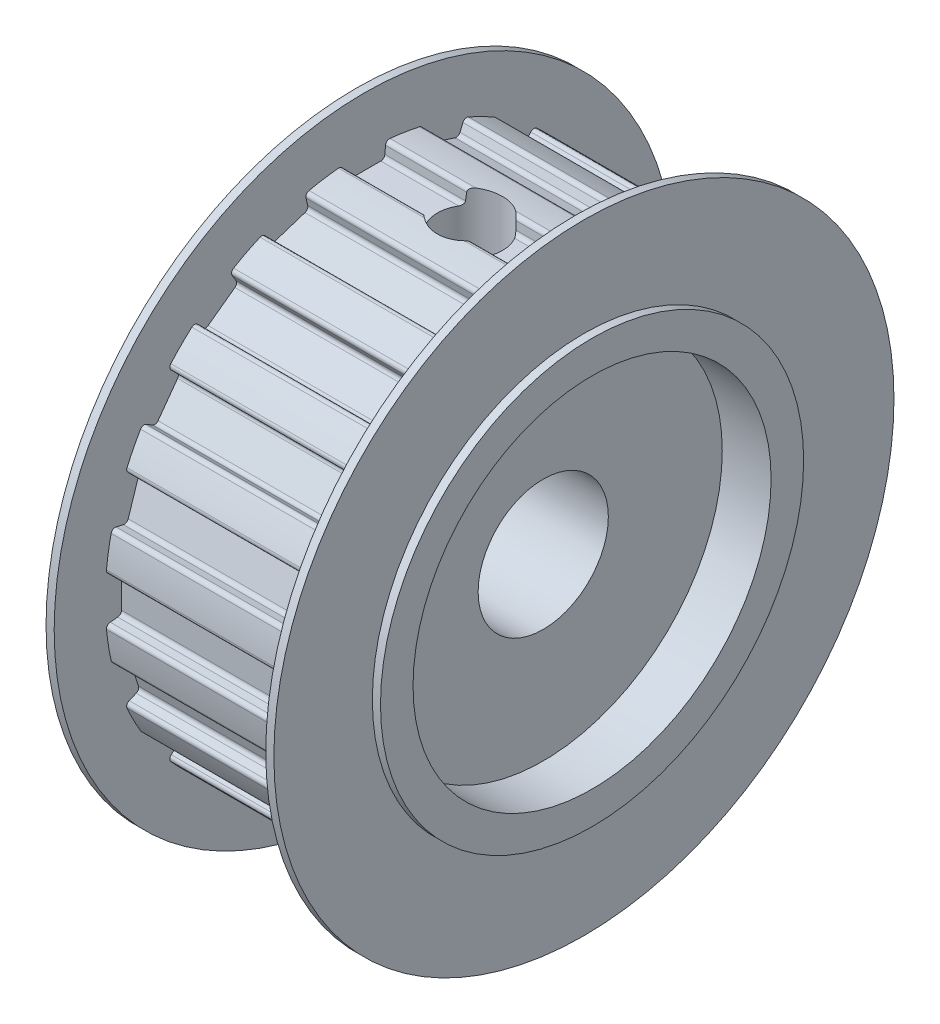
from build123d import *

# Parameters (mm, degrees)
ESQUISSE1_R                         = 15.915
EXTRUSION1_DEPTH                    = 13
ENL_V_MAT_EXTRU_2_DEPTH             = 13
CONG_1_R                            = 0.25
CONG_2_R                            = 0.25
CONG_3_R                            = 0.25
CONG_4_R                            = 0.25
R_P_TITION_CIRCULAIRE1_COUNT        = 20
CONG_1_OF_R_P_TITION_CIRCULAIRE1_R  = 0.25
CONG_2_OF_R_P_TITION_CIRCULAIRE1_R  = 0.25
CONG_3_OF_R_P_TITION_CIRCULAIRE1_R  = 0.25
CONG_4_OF_R_P_TITION_CIRCULAIRE1_R  = 0.25
ESQUISSE23_R                        = 19.05
EXTRUSION2_DEPTH                    = 1
ESQUISSE24_R                        = 19.05
EXTRUSION3_DEPTH                    = 1
ESQUISSE25_R                        = 4
ENL_V_MAT_EXTRU_3_DEPTH             = 16
ENL_V_MAT_EXTRU_5_REACH             = 35.965
ESQUISSE30_R                        = 2
ENL_V_MAT_EXTRU_5_DIRECTION_2_DEPTH = 5.135
ESQUISSE31_OUTSIDE_W                = 51.286
ESQUISSE31_OUTSIDE_H                = 51.286
ESQUISSE31_OUTSIDE_R                = 13
ENL_V_MAT_EXTRU_6_DEPTH             = 0.5
ESQUISSE32_OUTSIDE_W                = 51.286
ESQUISSE32_OUTSIDE_H                = 51.286
ESQUISSE32_OUTSIDE_R                = 13
ENL_V_MAT_EXTRU_7_DEPTH             = 0.5
CHANFREIN1_SIZE                     = 0.25
CHANFREIN2_SIZE                     = 0.25
ESQUISSE33_R                        = 11
EXTRUSION4_DEPTH                    = 3


with BuildPart() as part:
    # Esquisse1 → Extrusion1 (new body)
    with BuildSketch(Plane(origin=(0, 0, 0), x_dir=(0, 0, -1), z_dir=(1, 0, 0))):
        Circle(ESQUISSE1_R)
    extrude(amount=EXTRUSION1_DEPTH)

    # Esquisse22 → Enlèv. mat.-Extru.2 (cut)
    with BuildSketch(Plane.ZY):
        Polygon((-1.25, 14.915), (1.25, 14.915), (2.12662356, 25.374872317), (-2.12713714, 25.381000349), align=None)
    enl_v_mat_extru_2 = extrude(amount=-ENL_V_MAT_EXTRU_2_DEPTH, mode=Mode.SUBTRACT)

    # Congé1
    cong_1_edges = [part.edges().sort_by_distance(p)[0] for p in [
        (6.5, 14.915, -1.25),
    ]]
    fillet(cong_1_edges, radius=CONG_1_R)

    # Congé2
    cong_2_edges = [part.edges().sort_by_distance(p)[0] for p in [
        (6.5, 15.859400654, -1.329148563),
    ]]
    fillet(cong_2_edges, radius=CONG_2_R)

    # Congé3
    cong_3_edges = [part.edges().sort_by_distance(p)[0] for p in [
        (6.5, 14.915, 1.25),
    ]]
    fillet(cong_3_edges, radius=CONG_3_R)

    # Congé4
    cong_4_edges = [part.edges().sort_by_distance(p)[0] for p in [
        (6.5, 15.859400654, 1.329148563),
    ]]
    fillet(cong_4_edges, radius=CONG_4_R)

    # Répétition circulaire1: Enlèv. mat.-Extru.2 ×20 about axis
    r_p_tition_circulaire1_axis = Axis((0, 0, 0), (1, 0, 0))
    for i in range(1, R_P_TITION_CIRCULAIRE1_COUNT):
        add(enl_v_mat_extru_2.rotate(r_p_tition_circulaire1_axis, i * 360 / R_P_TITION_CIRCULAIRE1_COUNT), mode=Mode.SUBTRACT)

    # Congé1 of Répétition circulaire1
    cong_1_of_r_p_tition_circulaire1_edges = [part.edges().sort_by_distance(p)[0] for p in [
        (6.5, 14.571279184, 3.420167826),
        (6.5, 12.801220036, 7.755545795),
        (6.5, 9.778088281, 11.331756906),
        (6.5, 5.797809116, 13.798736698),
        (6.5, 1.25, 14.915),
        (6.5, -3.420167826, 14.571279184),
        (6.5, -7.755545795, 12.801220036),
        (6.5, -11.331756906, 9.778088281),
        (6.5, -13.798736698, 5.797809116),
        (6.5, -14.915, 1.25),
        (6.5, -14.571279184, -3.420167826),
        (6.5, -12.801220036, -7.755545795),
        (6.5, -9.778088281, -11.331756906),
        (6.5, -5.797809116, -13.798736698),
        (6.5, -1.25, -14.915),
        (6.5, 3.420167826, -14.571279184),
        (6.5, 7.755545795, -12.801220036),
        (6.5, 11.331756906, -9.778088281),
        (6.5, 13.798736698, -5.797809116),
    ]]
    fillet(cong_1_of_r_p_tition_circulaire1_edges, radius=CONG_1_OF_R_P_TITION_CIRCULAIRE1_R)

    # Congé2 of Répétition circulaire1
    cong_2_of_r_p_tition_circulaire1_edges = [part.edges().sort_by_distance(p)[0] for p in [
        (6.5, 15.49391583, 3.636728921),
        (6.5, 13.611778573, 8.246618039),
        (6.5, 10.39722559, 12.049270726),
        (6.5, 6.164919725, 14.672456842),
        (6.5, 1.329148563, 15.859400654),
        (6.5, -3.636728921, 15.49391583),
        (6.5, -8.246618039, 13.611778573),
        (6.5, -12.049270726, 10.39722559),
        (6.5, -14.672456842, 6.164919725),
        (6.5, -15.859400654, 1.329148563),
        (6.5, -15.49391583, -3.636728921),
        (6.5, -13.611778573, -8.246618039),
        (6.5, -10.39722559, -12.049270726),
        (6.5, -6.164919725, -14.672456842),
        (6.5, -1.329148563, -15.859400654),
        (6.5, 3.636728921, -15.49391583),
        (6.5, 8.246618039, -13.611778573),
        (6.5, 12.049270726, -10.39722559),
        (6.5, 14.672456842, -6.164919725),
    ]]
    fillet(cong_2_of_r_p_tition_circulaire1_edges, radius=CONG_2_OF_R_P_TITION_CIRCULAIRE1_R)

    # Congé3 of Répétition circulaire1
    cong_3_of_r_p_tition_circulaire1_edges = [part.edges().sort_by_distance(p)[0] for p in [
        (6.5, 13.798736698, 5.797809116),
        (6.5, 11.331756906, 9.778088281),
        (6.5, 7.755545795, 12.801220036),
        (6.5, 3.420167826, 14.571279184),
        (6.5, -1.25, 14.915),
        (6.5, -5.797809116, 13.798736698),
        (6.5, -9.778088281, 11.331756906),
        (6.5, -12.801220036, 7.755545795),
        (6.5, -14.571279184, 3.420167826),
        (6.5, -14.915, -1.25),
        (6.5, -13.798736698, -5.797809116),
        (6.5, -11.331756906, -9.778088281),
        (6.5, -7.755545795, -12.801220036),
        (6.5, -3.420167826, -14.571279184),
        (6.5, 1.25, -14.915),
        (6.5, 5.797809116, -13.798736698),
        (6.5, 9.778088281, -11.331756906),
        (6.5, 12.801220036, -7.755545795),
        (6.5, 14.571279184, -3.420167826),
    ]]
    fillet(cong_3_of_r_p_tition_circulaire1_edges, radius=CONG_3_OF_R_P_TITION_CIRCULAIRE1_R)

    # Congé4 of Répétition circulaire1
    cong_4_of_r_p_tition_circulaire1_edges = [part.edges().sort_by_distance(p)[0] for p in [
        (6.5, 14.672456842, 6.164919725),
        (6.5, 12.049270726, 10.39722559),
        (6.5, 8.246618039, 13.611778573),
        (6.5, 3.636728921, 15.49391583),
        (6.5, -1.329148563, 15.859400654),
        (6.5, -6.164919725, 14.672456842),
        (6.5, -10.39722559, 12.049270726),
        (6.5, -13.611778573, 8.246618039),
        (6.5, -15.49391583, 3.636728921),
        (6.5, -15.859400654, -1.329148563),
        (6.5, -14.672456842, -6.164919725),
        (6.5, -12.049270726, -10.39722559),
        (6.5, -8.246618039, -13.611778573),
        (6.5, -3.636728921, -15.49391583),
        (6.5, 1.329148563, -15.859400654),
        (6.5, 6.164919725, -14.672456842),
        (6.5, 10.39722559, -12.049270726),
        (6.5, 13.611778573, -8.246618039),
        (6.5, 15.49391583, -3.636728921),
    ]]
    fillet(cong_4_of_r_p_tition_circulaire1_edges, radius=CONG_4_OF_R_P_TITION_CIRCULAIRE1_R)

    # Esquisse23 → Extrusion2 (add)
    with BuildSketch(Plane.ZY):
        Circle(ESQUISSE23_R)
    extrude(amount=EXTRUSION2_DEPTH)

    # Esquisse24 → Extrusion3 (add)
    with BuildSketch(Plane(origin=(13, 0, 0), x_dir=(0, 0, -1), z_dir=(1, 0, 0))):
        Circle(ESQUISSE24_R)
    extrude(amount=EXTRUSION3_DEPTH)

    # Esquisse25 → Enlèv. mat.-Extru.3 (cut, through all)
    with BuildSketch(Plane.ZY.offset(1)):
        Circle(ESQUISSE25_R)
    extrude(amount=-ENL_V_MAT_EXTRU_3_DEPTH, mode=Mode.SUBTRACT)

    # Esquisse30 → Enlèv. mat.-Extru.5 (cut, up to next)
    with BuildSketch(Plane(origin=(0, 14.915, 0), x_dir=(-1, 0, 0), z_dir=(0, 1, 0)), mode=Mode.PRIVATE) as enl_v_mat_extru_5_sk1:
        with Locations((-6.5, 0)):
            Circle(ESQUISSE30_R)
    enl_v_mat_extru_5_tool1 = extrude(enl_v_mat_extru_5_sk1.sketch, amount=-ENL_V_MAT_EXTRU_5_REACH, mode=Mode.PRIVATE) & part.part
    add(enl_v_mat_extru_5_tool1.solids().sort_by_distance((6.5, 14.915, 0))[0], mode=Mode.SUBTRACT)

    # Esquisse30 → Enlèv. mat.-Extru.5 direction 2 (cut)
    with BuildSketch(Plane(origin=(0, 14.915, 0), x_dir=(-1, 0, 0), z_dir=(0, 1, 0))):
        with Locations((-6.5, 0)):
            Circle(ESQUISSE30_R)
    extrude(amount=ENL_V_MAT_EXTRU_5_DIRECTION_2_DEPTH, mode=Mode.SUBTRACT)

    # Esquisse31 outside → Enlèv. mat.-Extru.6 (cut)
    with BuildSketch(Plane.ZY.offset(1)):
        Rectangle(ESQUISSE31_OUTSIDE_W, ESQUISSE31_OUTSIDE_H)
        Circle(ESQUISSE31_OUTSIDE_R, mode=Mode.SUBTRACT)
    extrude(amount=-ENL_V_MAT_EXTRU_6_DEPTH, mode=Mode.SUBTRACT)

    # Esquisse32 outside → Enlèv. mat.-Extru.7 (cut)
    with BuildSketch(Plane(origin=(14, 0, 0), x_dir=(0, 0, -1), z_dir=(1, 0, 0))):
        Rectangle(ESQUISSE32_OUTSIDE_W, ESQUISSE32_OUTSIDE_H)
        Circle(ESQUISSE32_OUTSIDE_R, mode=Mode.SUBTRACT)
    extrude(amount=-ENL_V_MAT_EXTRU_7_DEPTH, mode=Mode.SUBTRACT)

    # Chanfrein1
    chanfrein1_edges = [part.edges().sort_by_distance(p)[0] for p in [
        (14, 0, -4),
    ]]
    chamfer(chanfrein1_edges, length=CHANFREIN1_SIZE)

    # Chanfrein2
    chanfrein2_edges = [part.edges().sort_by_distance(p)[0] for p in [
        (-1, 0, -4),
    ]]
    chamfer(chanfrein2_edges, length=CHANFREIN2_SIZE)

    # Esquisse33 → Extrusion4 (cut)
    with BuildSketch(Plane(origin=(14, 0, 0), x_dir=(0, 0, -1), z_dir=(1, 0, 0))):
        Circle(ESQUISSE33_R)
    extrude(amount=-EXTRUSION4_DEPTH, mode=Mode.SUBTRACT)


solid = part.part
